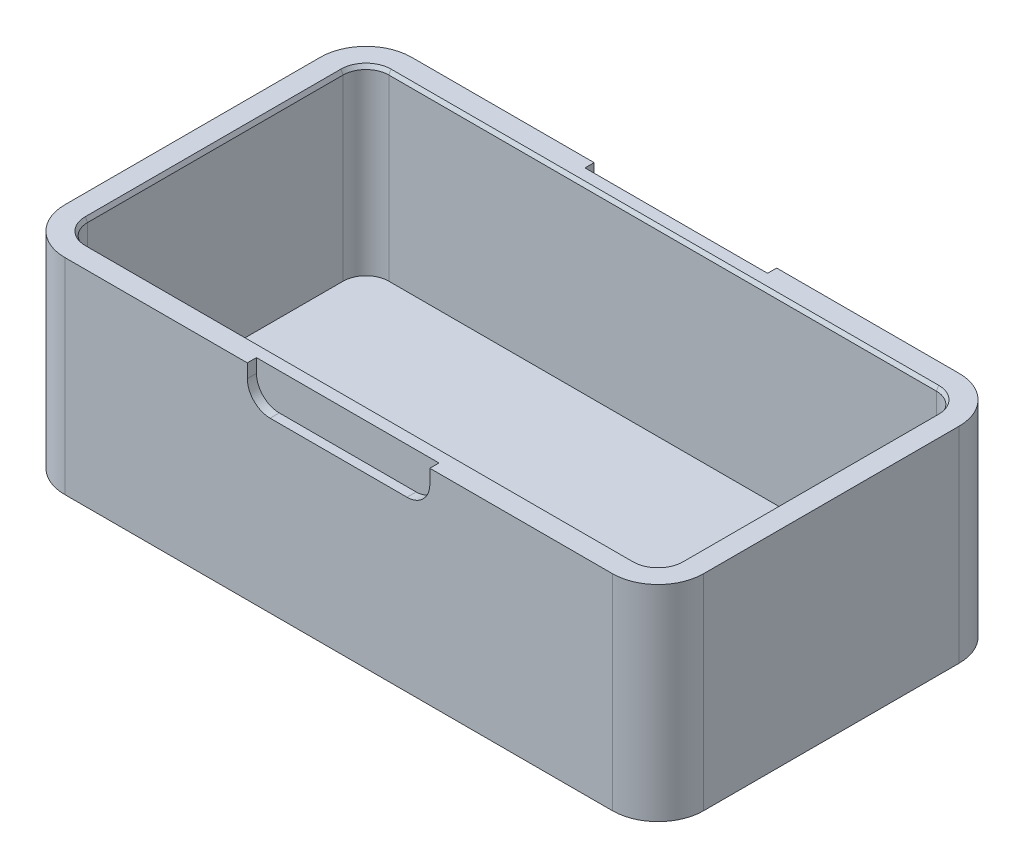
from build123d import *

# Parameters (mm, degrees)
SKETCH1_W            = 140
SKETCH1_H            = 76
BOSS_EXTRUDE1_DEPTH  = 45
FILLET2_R            = 10
CUT_EXTRUDE2_DEPTH   = 40
SKETCH5_W            = 40
SKETCH5_H            = 8
CUT_EXTRUDE3_DEPTH   = 2
FILLET3_R            = 5
FILLET3_OF_MIRROR1_R = 5
CHAMFER1_SIZE        = 0.5
CHAMFER1_SIZE2       = 0.866025404


with BuildPart() as part:
    # Sketch1 → Boss-Extrude1 (new body)
    with BuildSketch(Plane(origin=(0, 0, 0), x_dir=(1, 0, 0), z_dir=(0, 1, 0))):
        with Locations((70, 38)):
            Rectangle(SKETCH1_W, SKETCH1_H)
    extrude(amount=BOSS_EXTRUDE1_DEPTH)

    # Fillet2
    fillet2_edges = [part.edges().sort_by_distance(p)[0] for p in [
        (0, 22.5, -76),
        (140, 22.5, -76),
        (140, 22.5, 0),
        (0, 22.5, 0),
    ]]
    fillet(fillet2_edges, radius=FILLET2_R)

    # Sketch4 → Cut-Extrude2 (cut)
    with BuildSketch(Plane(origin=(0, 45, 0), x_dir=(1, 0, 0), z_dir=(0, 1, 0))):
        with BuildLine():
            Line((135, 10), (135, 66))
            ThreePointArc((135, 66), (133.535533906, 69.535533906), (130, 71))
            Line((130, 71), (10, 71))
            ThreePointArc((10, 71), (6.464466094, 69.535533906), (5, 66))
            Line((5, 66), (5, 10))
            ThreePointArc((5, 10), (6.464466094, 6.464466094), (10, 5))
            Line((10, 5), (130, 5))
            ThreePointArc((130, 5), (133.535533906, 6.464466094), (135, 10))
        make_face()
    extrude(amount=-CUT_EXTRUDE2_DEPTH, mode=Mode.SUBTRACT)

    # Sketch5 → Cut-Extrude3 (cut)
    with BuildSketch(Plane.XY):
        with Locations((70, 41)):
            Rectangle(SKETCH5_W, SKETCH5_H)
    cut_extrude3 = extrude(amount=-CUT_EXTRUDE3_DEPTH, mode=Mode.SUBTRACT)

    # Fillet3
    fillet3_edges = [part.edges().sort_by_distance(p)[0] for p in [
        (50, 37, -1),
        (90, 37, -1),
    ]]
    fillet(fillet3_edges, radius=FILLET3_R)

    # Mirror1: Cut-Extrude3 across plane
    add(cut_extrude3.mirror(Plane.XY.offset(-38)), mode=Mode.SUBTRACT)

    # Fillet3 of Mirror1
    fillet3_of_mirror1_edges = [part.edges().sort_by_distance(p)[0] for p in [
        (50, 37, -75),
        (90, 37, -75),
    ]]
    fillet(fillet3_of_mirror1_edges, radius=FILLET3_OF_MIRROR1_R)

    # Chamfer1
    chamfer1_edges = [part.edges().sort_by_distance(p)[0] for p in [
        (133.535533906, 45, -6.464466094),
        (135, 45, -38),
        (133.535533906, 45, -69.535533906),
        (70, 45, -71),
        (6.464466094, 45, -69.535533906),
        (5, 45, -38),
        (6.464466094, 45, -6.464466094),
        (70, 45, -5),
    ]]
    chamfer1_side = [part.faces().sort_by_distance(p)[0] for p in [
        (4.055342415, 45, -4.055342415),
    ]]
    chamfer(chamfer1_edges, length=CHAMFER1_SIZE, length2=CHAMFER1_SIZE2, reference=chamfer1_side[0])


solid = part.part
